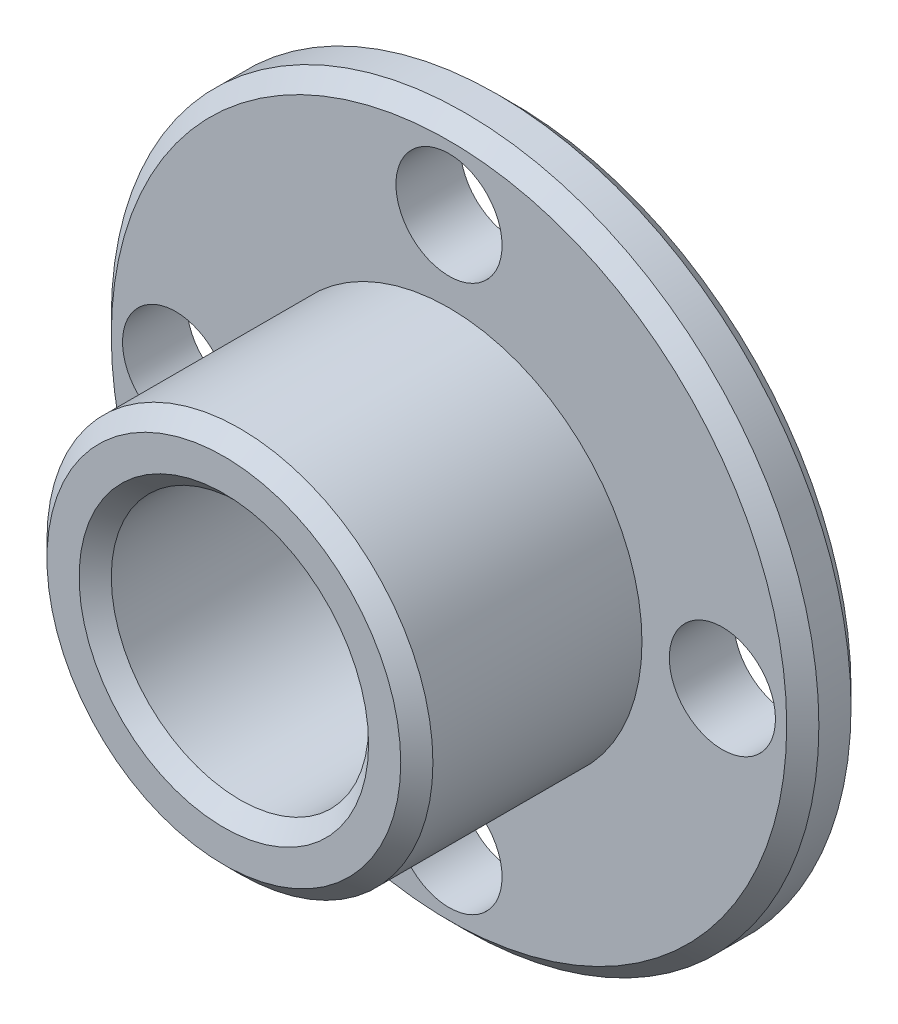
from build123d import *

# Parameters (mm, degrees)
ESQUISSE1_R        = 11
ESQUISSE1_R_2      = 4
ESQUISSE1_R_3      = 1.65
BOSS_EXTRU_1_DEPTH = 2
ESQUISSE2_R        = 6
ESQUISSE2_R_2      = 4
BOSS_EXTRU_2_DEPTH = 7
CHANFREIN1_SIZE    = 0.5


with BuildPart() as part:
    # Esquisse1 → Boss.-Extru.1 (new body)
    with BuildSketch(Plane.XY):
        with Locations((65.66793974, 39.535817655)):
            Circle(ESQUISSE1_R)
        with Locations((65.66793974, 39.535817655)):
            Circle(ESQUISSE1_R_2, mode=Mode.SUBTRACT)
        with Locations((65.66793974, 48.035817655)):
            Circle(ESQUISSE1_R_3, mode=Mode.SUBTRACT)
        with Locations((74.16793974, 39.535817655)):
            Circle(ESQUISSE1_R_3, mode=Mode.SUBTRACT)
        with Locations((65.66793974, 31.035817655)):
            Circle(ESQUISSE1_R_3, mode=Mode.SUBTRACT)
        with Locations((57.16793974, 39.535817655)):
            Circle(ESQUISSE1_R_3, mode=Mode.SUBTRACT)
    extrude(amount=BOSS_EXTRU_1_DEPTH)

    # Esquisse2 → Boss.-Extru.2 (add)
    with BuildSketch(Plane.XY.offset(2)):
        with Locations((65.66793974, 39.535817655)):
            Circle(ESQUISSE2_R)
        with Locations((65.66793974, 39.535817655)):
            Circle(ESQUISSE2_R_2, mode=Mode.SUBTRACT)
    extrude(amount=BOSS_EXTRU_2_DEPTH)

    # Chanfrein1
    chanfrein1_edges = [part.edges().sort_by_distance(p)[0] for p in [
        (54.66793974, 39.535817655, 0),
        (59.66793974, 39.535817655, 9),
        (61.66793974, 39.535817655, 9),
        (54.66793974, 39.535817655, 2),
    ]]
    chamfer(chanfrein1_edges, length=CHANFREIN1_SIZE)


solid = part.part
